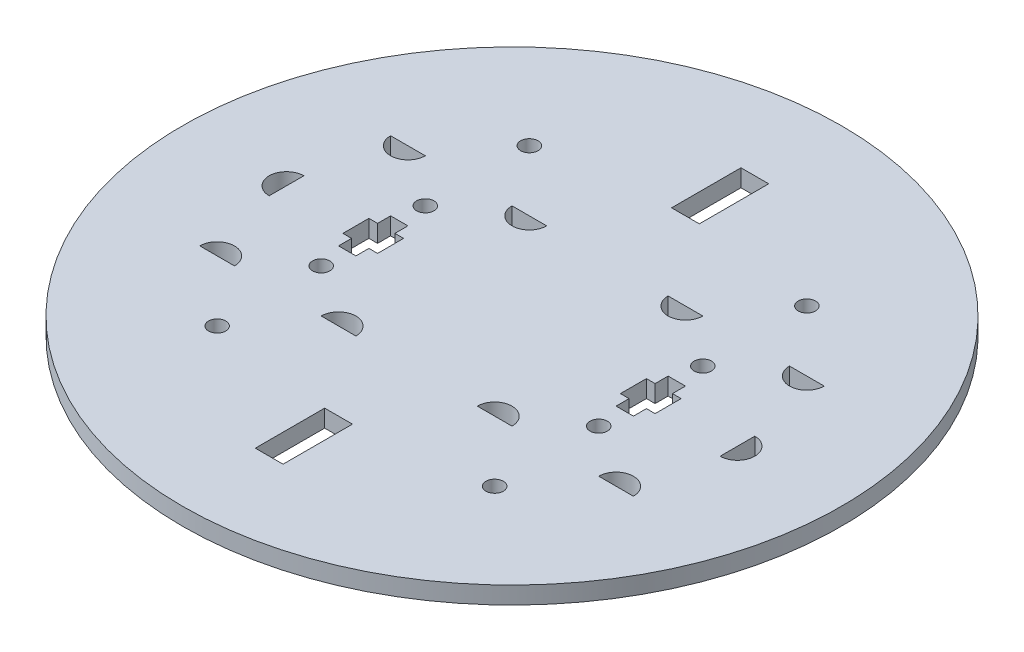
from build123d import *

# Parameters (mm, degrees)
SKETCH1_R      = 9.5
SKETCH1_R_2    = 0.25
SKETCH1_W      = 0.8
SKETCH1_H      = 2
EXTRUDE1_DEPTH = 0.5
SKETCH2_R      = 0.25
EXTRUDE2_DEPTH = 1.5


with BuildPart() as part:
    # Sketch1 → Extrude1 (new body)
    with BuildSketch(Plane(origin=(0, 0, 0), x_dir=(1, 0, 0), z_dir=(0, 1, 0))):
        Circle(SKETCH1_R)
        with Locations((-4, 4.5)):
            Circle(SKETCH1_R_2, mode=Mode.SUBTRACT)
        with Locations((4, 4.5)):
            Circle(SKETCH1_R_2, mode=Mode.SUBTRACT)
        with Locations((4, -4.5)):
            Circle(SKETCH1_R_2, mode=Mode.SUBTRACT)
        with Locations((-4, -4.5)):
            Circle(SKETCH1_R_2, mode=Mode.SUBTRACT)
        with Locations((0, 6)):
            Rectangle(SKETCH1_W, SKETCH1_H, mode=Mode.SUBTRACT)
        with Locations((0, -6)):
            Rectangle(SKETCH1_W, SKETCH1_H, mode=Mode.SUBTRACT)
    extrude(amount=EXTRUDE1_DEPTH)

    # Sketch2 → Extrude2 (cut, through all)
    with BuildSketch(Plane(origin=(0, 0, 0), x_dir=(1, 0, 0), z_dir=(0, 1, 0))):
        with Locations((4, 1.5)):
            Circle(SKETCH2_R)
        with Locations((4, -1.5)):
            Circle(SKETCH2_R)
        with Locations((-4, 1.5)):
            Circle(SKETCH2_R)
        with Locations((-4, -1.5)):
            Circle(SKETCH2_R)
        Polygon((3.75, 0.75), (4.25, 0.75), (4.25, 0.375), (4.5, 0.375), (4.5, -0.375), (4.25, -0.375), (4.25, -0.75), (3.75, -0.75), (3.75, -0.375), (3.5, -0.375), (3.5, 0.375), (3.75, 0.375), align=None)
        Polygon((-3.5, 0.375), (-3.5, -0.375), (-3.75, -0.375), (-3.75, -0.75), (-4.25, -0.75), (-4.25, -0.375), (-4.5, -0.375), (-4.5, 0.375), (-4.25, 0.375), (-4.25, 0.75), (-3.75, 0.75), (-3.75, 0.375), align=None)
        with BuildLine():
            Line((-6.5, 0.5), (-6.5, -0.5))
            ThreePointArc((-6.5, -0.5), (-7, 0), (-6.5, 0.5))
        make_face()
        with BuildLine():
            Line((6.5, 0.5), (6.5, -0.5))
            ThreePointArc((6.5, -0.5), (7, 0), (6.5, 0.5))
        make_face()
        with BuildLine():
            Line((-6.25, 2.75), (-5.25, 2.75))
            ThreePointArc((-5.25, 2.75), (-5.75, 2.25), (-6.25, 2.75))
        make_face()
        with BuildLine():
            Line((-2.75, 2.75), (-1.75, 2.75))
            ThreePointArc((-1.75, 2.75), (-2.25, 2.25), (-2.75, 2.75))
        make_face()
        with BuildLine():
            Line((1.75, 2.75), (2.75, 2.75))
            ThreePointArc((2.75, 2.75), (2.25, 2.25), (1.75, 2.75))
        make_face()
        with BuildLine():
            Line((5.25, 2.75), (6.25, 2.75))
            ThreePointArc((6.25, 2.75), (5.75, 2.25), (5.25, 2.75))
        make_face()
        with BuildLine():
            Line((-6.25, -2.75), (-5.25, -2.75))
            ThreePointArc((-5.25, -2.75), (-5.75, -2.25), (-6.25, -2.75))
        make_face()
        with BuildLine():
            Line((-2.75, -2.75), (-1.75, -2.75))
            ThreePointArc((-1.75, -2.75), (-2.25, -2.25), (-2.75, -2.75))
        make_face()
        with BuildLine():
            Line((1.75, -2.75), (2.75, -2.75))
            ThreePointArc((2.75, -2.75), (2.25, -2.25), (1.75, -2.75))
        make_face()
        with BuildLine():
            Line((5.25, -2.75), (6.25, -2.75))
            ThreePointArc((6.25, -2.75), (5.75, -2.25), (5.25, -2.75))
        make_face()
    extrude(amount=EXTRUDE2_DEPTH, mode=Mode.SUBTRACT)


solid = part.part
